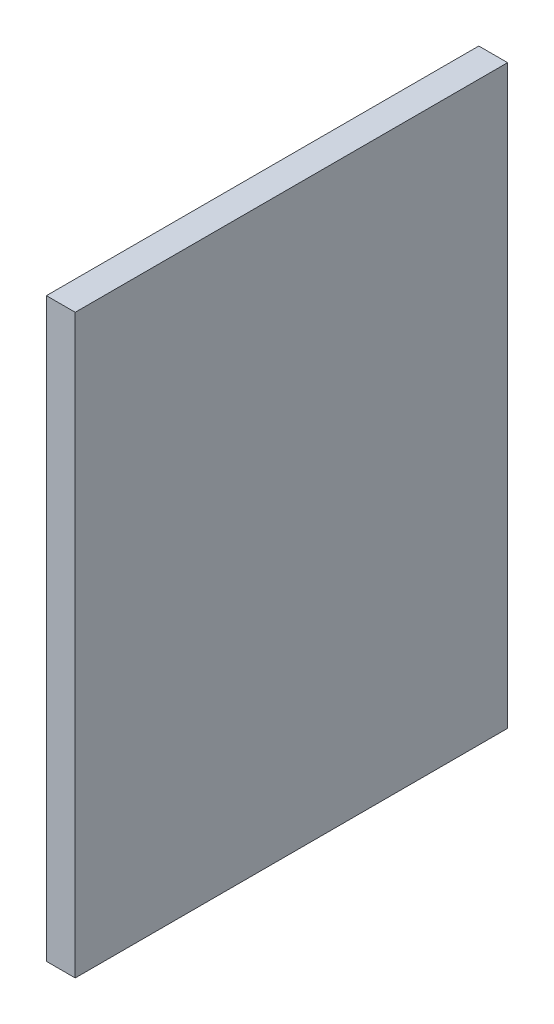
from build123d import *

# Parameters (mm, degrees)
SKETCH_1_W      = 900
SKETCH_1_H      = 1200
EXTRUDE_1_DEPTH = 60


with BuildPart() as part:
    # Эскиз1 → Бобышка-Вытянуть1 (new body)
    with BuildSketch(Plane(origin=(0, 0, 0), x_dir=(0, 0, -1), z_dir=(1, 0, 0))):
        with Locations((450, 600)):
            Rectangle(SKETCH_1_W, SKETCH_1_H)
    extrude(amount=EXTRUDE_1_DEPTH)


solid = part.part
